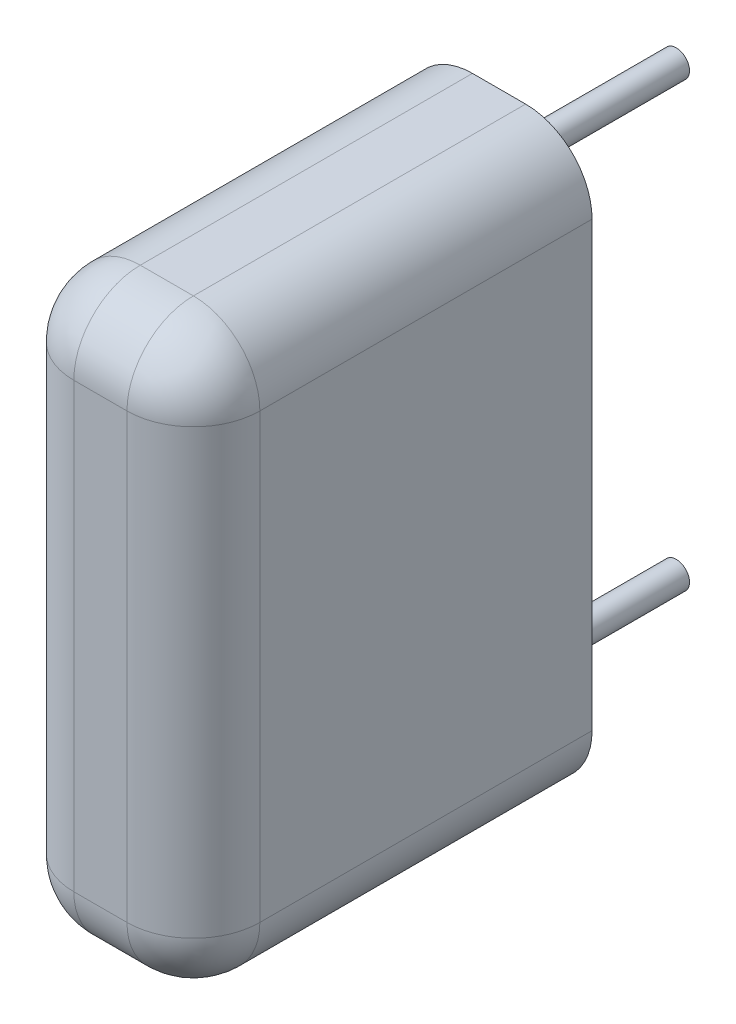
from build123d import *

# Parameters (mm, degrees)
SKETCH_2_W      = 4.2
SKETCH_2_H      = 13
EXTRUDE_1_DEPTH = 9
SKETCH_3_R      = 0.3
EXTRUDE_2_DEPTH = 4
FILLET_1_R      = 1.5


with BuildPart() as part:
    # Эскиз2 → Бобышка-Вытянуть1 (new body)
    with BuildSketch(Plane.XY):
        with Locations((0, -5)):
            Rectangle(SKETCH_2_W, SKETCH_2_H)
    extrude(amount=EXTRUDE_1_DEPTH)

    # Эскиз3 → Бобышка-Вытянуть2 (add)
    with BuildSketch(Plane(origin=(0, 0, 0), x_dir=(-1, 0, 0), z_dir=(0, 0, -1))):
        Circle(SKETCH_3_R)
        with Locations((0, -10)):
            Circle(SKETCH_3_R)
    extrude(amount=EXTRUDE_2_DEPTH)

    # Скругление1
    fillet_1_edges = [part.edges().sort_by_distance(p)[0] for p in [
        (2.1, -5, 9),
        (0, 1.5, 9),
        (-2.1, -5, 9),
        (0, -11.5, 9),
        (-2.1, 1.5, 4.5),
        (2.1, 1.5, 4.5),
        (2.1, -11.5, 4.5),
        (-2.1, -11.5, 4.5),
    ]]
    fillet(fillet_1_edges, radius=FILLET_1_R)


solid = part.part
